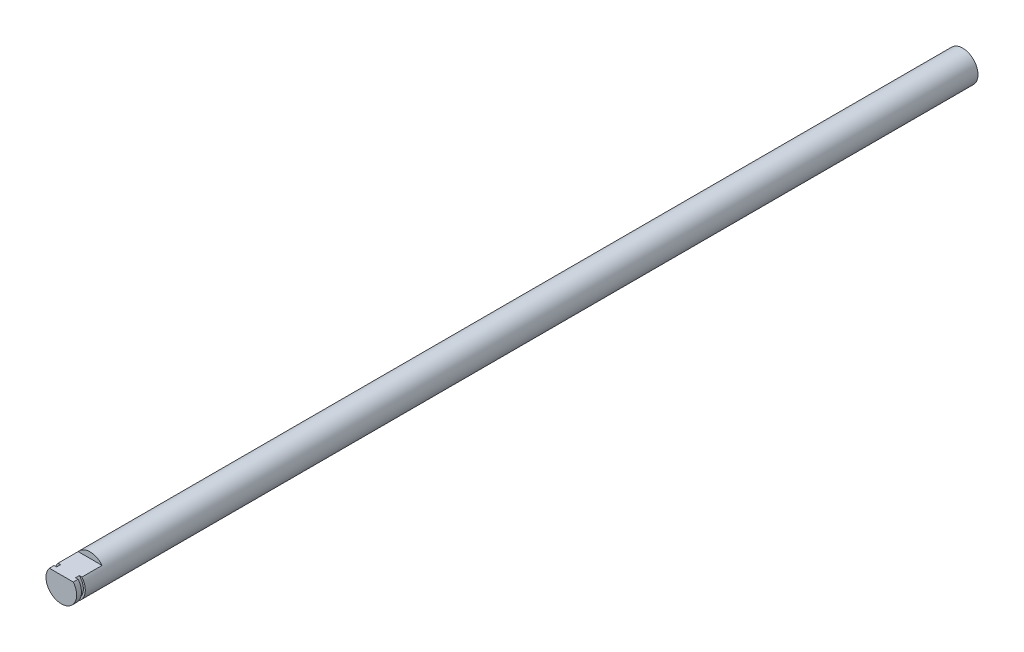
from build123d import *

# Parameters (mm, degrees)
SKETCH1_R           = 4
BOSS_EXTRUDE1_DEPTH = 235
CUT_EXTRUDE1_DEPTH  = 7.5
SKETCH3_R           = 4
SKETCH3_R_2         = 3.5
CUT_EXTRUDE2_DEPTH  = 1


with BuildPart() as part:
    # Sketch1 → Boss-Extrude1 (new body)
    with BuildSketch(Plane.XY):
        Circle(SKETCH1_R)
    extrude(amount=BOSS_EXTRUDE1_DEPTH)

    # Sketch2 → Cut-Extrude1 (cut)
    with BuildSketch(Plane.XY.offset(235)):
        with BuildLine():
            Line((3.122498999, 2.5), (-3.122498999, 2.5))
            ThreePointArc((-3.122498999, 2.5), (0, 4), (3.122498999, 2.5))
        make_face()
    extrude(amount=-CUT_EXTRUDE1_DEPTH, mode=Mode.SUBTRACT)

    # Sketch3 → Cut-Extrude2 (cut)
    with BuildSketch(Plane.XY.offset(233.75)):
        Circle(SKETCH3_R)
        Circle(SKETCH3_R_2, mode=Mode.SUBTRACT)
    extrude(amount=-CUT_EXTRUDE2_DEPTH, mode=Mode.SUBTRACT)


solid = part.part
